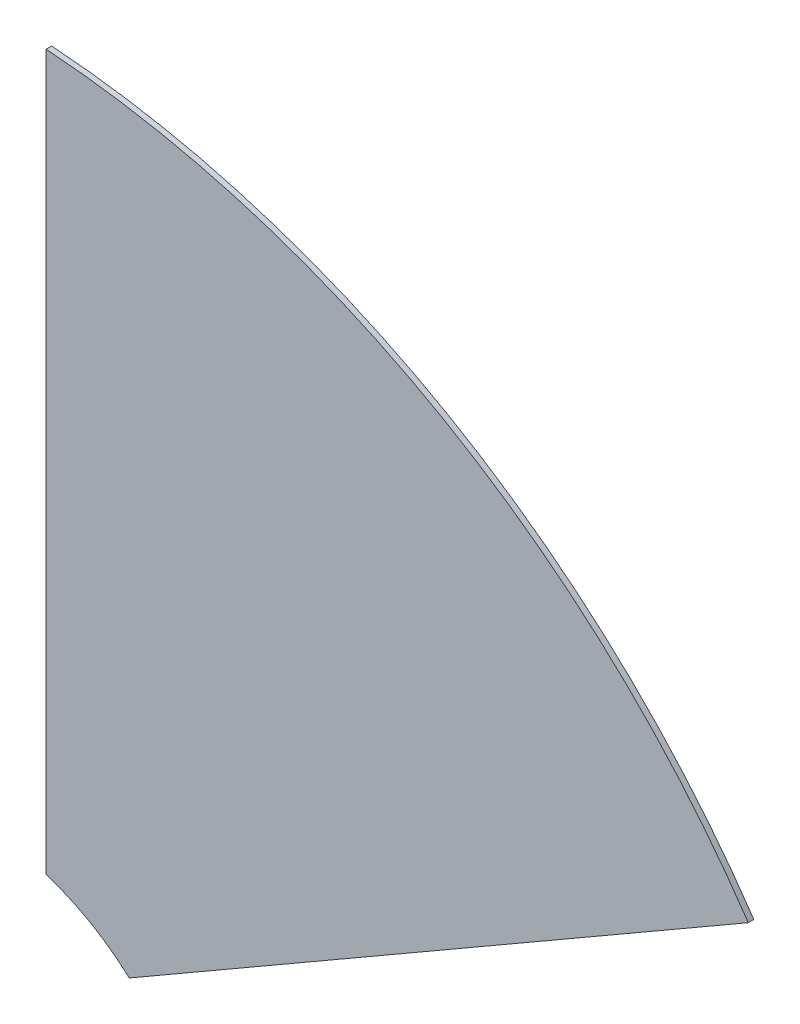
from build123d import *

# Parameters (mm, degrees)
BOSS_EXTRUDE1_DEPTH = 1.5875


with BuildPart() as part:
    # Sketch2 → Boss-Extrude1 (new body)
    with BuildSketch(Plane.XY):
        with BuildLine():
            Line((19.05, 266.018772834), (19.05, 60.57513929))
            ThreePointArc((19.05, 60.57513929), (31.75, 54.99261314), (42.934609463, 46.785353587))
            Line((42.934609463, 46.785353587), (220.854015158, 149.507170359))
            ThreePointArc((220.854015158, 149.507170359), (133.35, 230.968975189), (19.05, 266.018772834))
        make_face()
    extrude(amount=BOSS_EXTRUDE1_DEPTH)


solid = part.part
